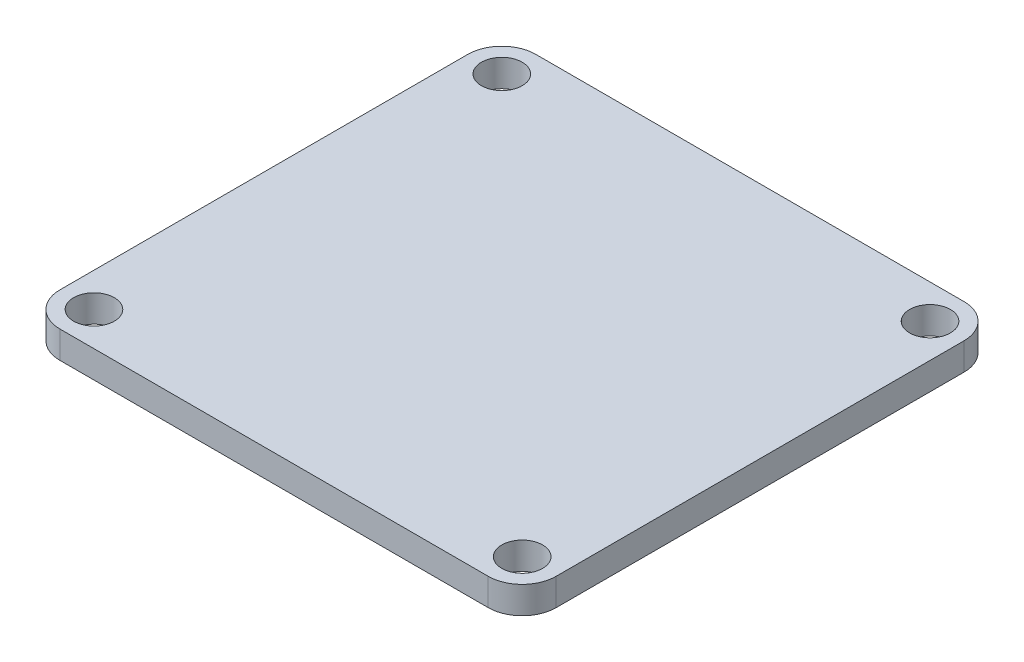
from build123d import *

# Parameters (mm, degrees)
SKETCH2_R           = 3
BOSS_EXTRUDE1_DEPTH = 4


with BuildPart() as part:
    # Sketch2 → Boss-Extrude1 (new body)
    with BuildSketch(Plane(origin=(0, 0, 0), x_dir=(1, 0, 0), z_dir=(0, 1, 0))):
        with BuildLine():
            Line((-31.5, -35), (31.5, -35))
            ThreePointArc((31.5, -35), (35.035533906, -33.535533906), (36.5, -30))
            Line((36.5, -30), (36.5, 30))
            ThreePointArc((36.5, 30), (35.035533906, 33.535533906), (31.5, 35))
            Line((31.5, 35), (-31.5, 35))
            ThreePointArc((-31.5, 35), (-35.035533906, 33.535533906), (-36.5, 30))
            Line((-36.5, 30), (-36.5, -30))
            ThreePointArc((-36.5, -30), (-35.035533906, -33.535533906), (-31.5, -35))
        make_face()
        with Locations((-31.5, 30)):
            Circle(SKETCH2_R, mode=Mode.SUBTRACT)
        with Locations((-31.5, -30)):
            Circle(SKETCH2_R, mode=Mode.SUBTRACT)
        with Locations((31.5, 30)):
            Circle(SKETCH2_R, mode=Mode.SUBTRACT)
        with Locations((31.5, -30)):
            Circle(SKETCH2_R, mode=Mode.SUBTRACT)
    extrude(amount=BOSS_EXTRUDE1_DEPTH)


solid = part.part
